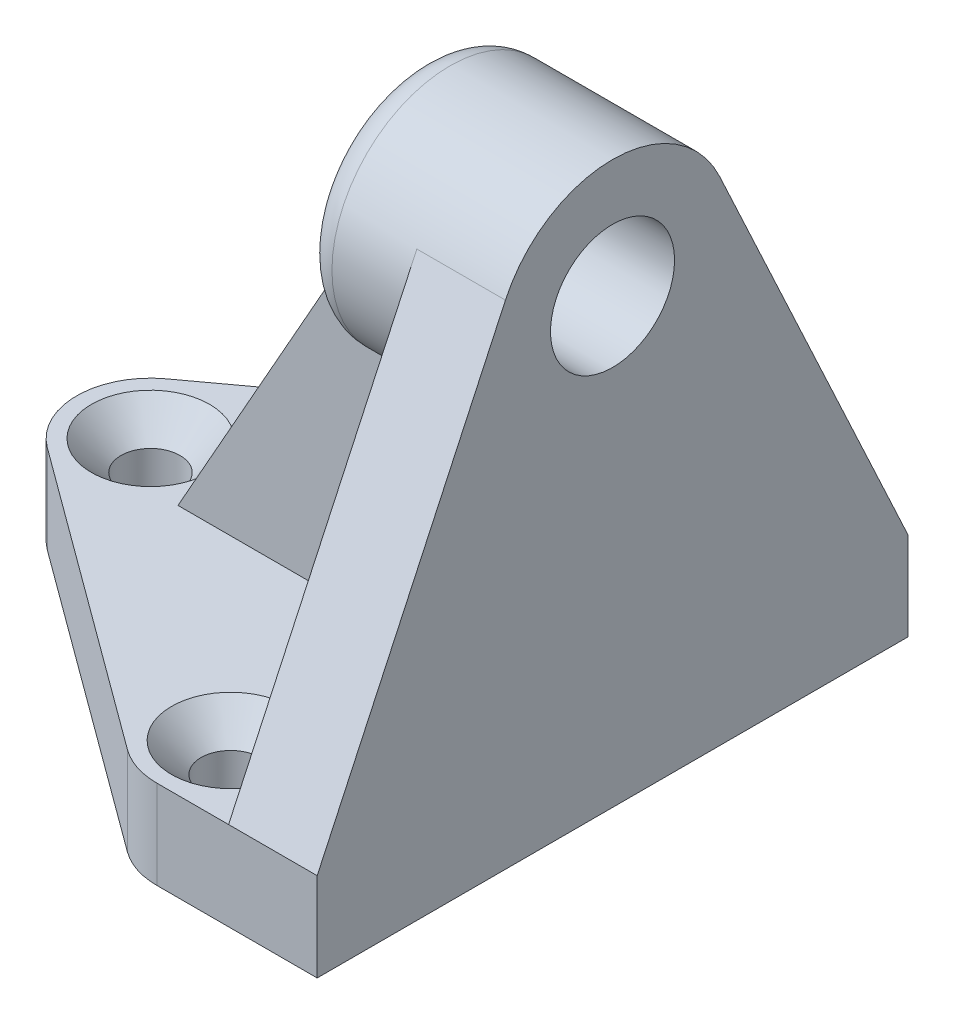
from build123d import *

# Parameters (mm, degrees)
SKETCH_1_R           = 2
EXTRUDE_1_DEPTH      = 6
CHAMFER_3_SIZE       = 2
SKETCH_4_R           = 4.2
EXTRUDE_2_DEPTH      = 6
SKETCH_7_R           = 8
EXTRUDE_3_DEPTH      = 7
FILLET_1_R           = 2
EXTRUDE_4_DEPTH      = 3
EXTRUDE_4_DEPTH_BACK = 3
SKETCH_9_R           = 4.2
CUT_EXTRUDE_1_DEPTH  = 10


with BuildPart() as part:
    # Эскиз1 → Бобышка-Вытянуть1 (new body)
    with BuildSketch(Plane(origin=(0, 0, 0), x_dir=(1, 0, 0), z_dir=(0, 1, 0))):
        with BuildLine():
            Line((0, -20), (0, 20))
            Line((0, 20), (-10.861288353, 20))
            ThreePointArc((-10.861288353, 20), (-12.418498887, 19.751325642), (-13.820814088, 19.030038141))
            Line((-13.820814088, 19.030038141), (-34.246577377, 4.030038141))
            ThreePointArc((-34.246577377, 4.030038141), (-36.287051642, 0), (-34.246577377, -4.030038141))
            Line((-34.246577377, -4.030038141), (-13.820814088, -19.030038141))
            ThreePointArc((-13.820814088, -19.030038141), (-12.418498887, -19.751325642), (-10.861288353, -20))
            Line((-10.861288353, -20), (0, -20))
        make_face()
        with Locations((-31.287051642, 0)):
            Circle(SKETCH_1_R, mode=Mode.SUBTRACT)
        with Locations((-10.861288353, -15)):
            Circle(SKETCH_1_R, mode=Mode.SUBTRACT)
        with Locations((-10.861288353, 15)):
            Circle(SKETCH_1_R, mode=Mode.SUBTRACT)
    extrude(amount=EXTRUDE_1_DEPTH)

    # Фаска3
    chamfer_3_edges = [part.edges().sort_by_distance(p)[0] for p in [
        (-12.861288353, 6, -15),
        (-33.287051642, 6, 0),
        (-12.861288353, 6, 15),
    ]]
    chamfer(chamfer_3_edges, length=CHAMFER_3_SIZE)

    # Эскиз4 → Бобышка-Вытянуть2 (add)
    with BuildSketch(Plane(origin=(0, 0, 0), x_dir=(0, 0, -1), z_dir=(1, 0, 0))):
        with BuildLine():
            Line((-7.252328736, 33.376940613), (-20, 6))
            Line((-20, 6), (20, 6))
            Line((20, 6), (7.252328736, 33.376940613))
            ThreePointArc((7.252328736, 33.376940613), (0, 38), (-7.252328736, 33.376940613))
        make_face()
        with Locations((0, 30)):
            Circle(SKETCH_4_R, mode=Mode.SUBTRACT)
    extrude(amount=-EXTRUDE_2_DEPTH)

    # Эскиз7 → Бобышка-Вытянуть3 (add)
    with BuildSketch(Plane.ZY.offset(6)):
        with Locations((0, 30)):
            Circle(SKETCH_7_R)
    extrude(amount=EXTRUDE_3_DEPTH)

    # Скругление1
    fillet_1_edges = [part.edges().sort_by_distance(p)[0] for p in [
        (-13, 30, -8),
    ]]
    fillet(fillet_1_edges, radius=FILLET_1_R)

    # Эскиз8 → Бобышка-Вытянуть4 (add, two sides)
    with BuildSketch(Plane.XY) as extrude_4_sk:
        Polygon((-26.427051642, 6), (-12.606919313, 30.486720465), (-11.530283794, 30.486720465), (-11.530283794, 17.734425211), (-4.808903741, 17.734425211), (-4.214748598, 6), align=None)
    extrude(amount=EXTRUDE_4_DEPTH)
    extrude(extrude_4_sk.sketch, amount=-EXTRUDE_4_DEPTH_BACK)

    # Эскиз9 → Вырез-Вытянуть1 (cut)
    with BuildSketch(Plane(origin=(0, 0, 0), x_dir=(0, 0, -1), z_dir=(1, 0, 0))):
        with Locations((0, 30)):
            Circle(SKETCH_9_R)
    extrude(amount=-CUT_EXTRUDE_1_DEPTH, mode=Mode.SUBTRACT)


solid = part.part
